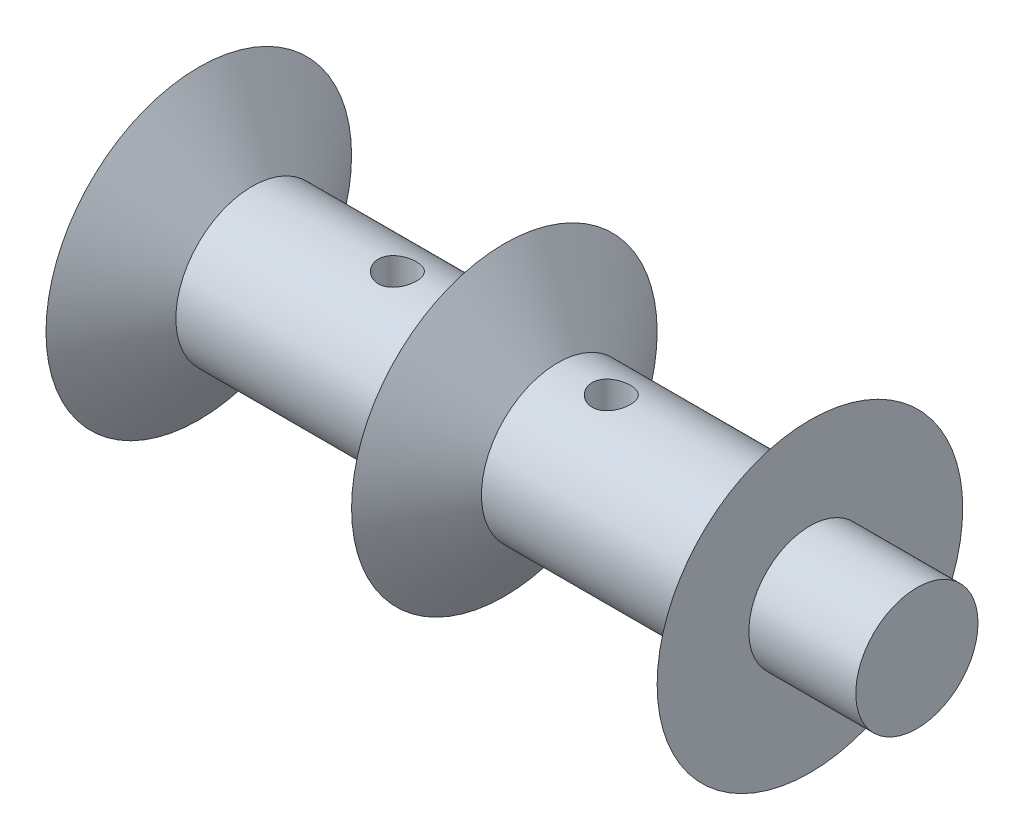
from build123d import *

# Parameters (mm, degrees)
CUT_EXTRUDE1_DEPTH      = 9
SKETCH3_R               = 2.5
CUT_EXTRUDE2_DEPTH      = 2.5
SKETCH4_R               = 4
BOSS_EXTRUDE1_DEPTH     = 7
SKETCH5_R               = 1.25
CUT_EXTRUDE3_DEPTH      = 11
CUT_EXTRUDE3_DEPTH_BACK = 11


with BuildPart() as part:
    # Sketch1 → Revolve1 (revolve)
    with BuildSketch(Plane.XY):
        Polygon((20, 0), (-20, 0), (-20, 10), (-16.5, 5), (-3.5, 5), (0, 10), (3.5, 5), (16.5, 5), (20, 10), align=None)
    revolve(axis=Axis((20, 0, 0), (-1, 0, 0)))

    # Sketch2 → Cut-Extrude1 (cut)
    with BuildSketch(Plane.ZY.offset(20)):
        with BuildLine():
            ThreePointArc((1.5, 2), (0, 2.5), (-1.5, 2))
            Line((-1.5, 2), (-1.5, -2))
            ThreePointArc((-1.5, -2), (0, -2.5), (1.5, -2))
            Line((1.5, -2), (1.5, 2))
        make_face()
    extrude(amount=-CUT_EXTRUDE1_DEPTH, mode=Mode.SUBTRACT)

    # Sketch3 → Cut-Extrude2 (cut)
    with BuildSketch(Plane.ZY.offset(20)):
        Circle(SKETCH3_R)
    extrude(amount=-CUT_EXTRUDE2_DEPTH, mode=Mode.SUBTRACT)

    # Sketch4 → Boss-Extrude1 (add)
    with BuildSketch(Plane(origin=(20, 0, 0), x_dir=(0, 0, -1), z_dir=(1, 0, 0))):
        Circle(SKETCH4_R)
    extrude(amount=BOSS_EXTRUDE1_DEPTH)

    # Sketch5 → Cut-Extrude3 (cut, two sides)
    with BuildSketch(Plane(origin=(0, 0, 0), x_dir=(1, 0, 0), z_dir=(0, 1, 0))) as cut_extrude3_sk:
        with Locations((-7, 0)):
            Circle(SKETCH5_R)
        with Locations((7, 0)):
            Circle(SKETCH5_R)
    extrude(amount=CUT_EXTRUDE3_DEPTH, mode=Mode.SUBTRACT)
    extrude(cut_extrude3_sk.sketch, amount=-CUT_EXTRUDE3_DEPTH_BACK, mode=Mode.SUBTRACT)


solid = part.part
